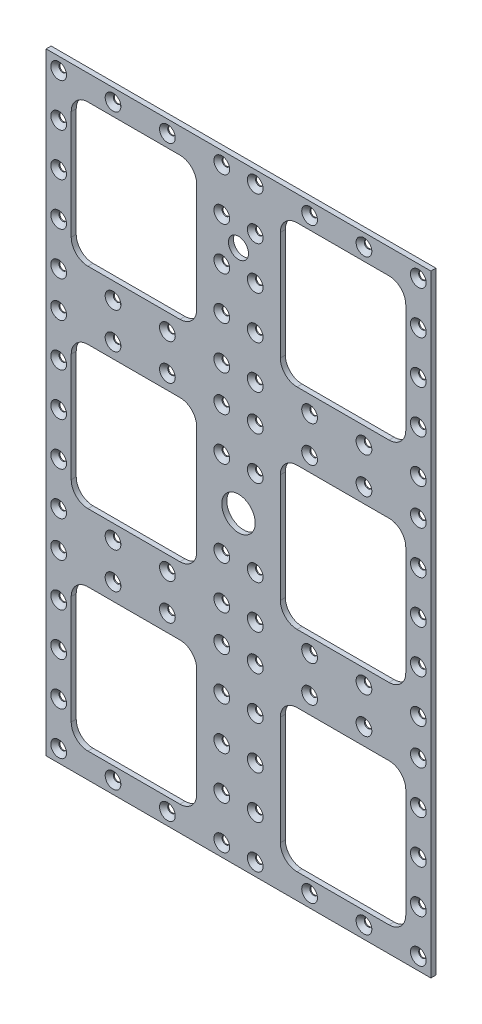
from build123d import *

# Parameters (mm, degrees)
SKETCH1_W                                      = 230
SKETCH1_H                                      = 366
BOSS_EXTRUDE1_DEPTH                            = 3
SKETCH2_W                                      = 75
SKETCH2_H                                      = 85
CUT_EXTRUDE4_DEPTH                             = 4
FILLET1_R                                      = 10
LPATTERN1_COUNT                                = 3
LPATTERN1_PITCH                                = 125.5
LPATTERN1_COUNT_DIR2                           = 2
LPATTERN1_PITCH_DIR2                           = 125
FILLET1_OF_LPATTERN1_R                         = 10
CUT_EXTRUDE7_REACH                             = 5
SKETCH23_R                                     = 10
CSK_FOR_M4_FLAT_HEAD_MACHINE_SCREW5_AT_2_COUNT = 2
CSK_FOR_M4_FLAT_HEAD_MACHINE_SCREW5_AT_2_PITCH = 32.5
CSK_FOR_M4_FLAT_HEAD_MACHINE_SCREW5_AT_3_COUNT = 2
CSK_FOR_M4_FLAT_HEAD_MACHINE_SCREW5_AT_3_PITCH = 65
CSK_FOR_M4_FLAT_HEAD_MACHINE_SCREW5_AT_4_COUNT = 2
CSK_FOR_M4_FLAT_HEAD_MACHINE_SCREW5_AT_4_PITCH = 25.65625
CSK_FOR_M4_FLAT_HEAD_MACHINE_SCREW5_AT_5_COUNT = 2
CSK_FOR_M4_FLAT_HEAD_MACHINE_SCREW5_AT_5_PITCH = 51.3125
CSK_FOR_M4_FLAT_HEAD_MACHINE_SCREW5_AT_6_COUNT = 2
CSK_FOR_M4_FLAT_HEAD_MACHINE_SCREW5_AT_6_PITCH = 76.96875
CSK_FOR_M4_FLAT_HEAD_MACHINE_SCREW5_AT_7_COUNT = 2
CSK_FOR_M4_FLAT_HEAD_MACHINE_SCREW5_AT_7_PITCH = 102.625
CSK_FOR_M4_FLAT_HEAD_MACHINE_SCREW5_AT_8_COUNT = 2
CSK_FOR_M4_FLAT_HEAD_MACHINE_SCREW5_AT_8_PITCH = 107.648226298
CSK_FOR_M4_FLAT_HEAD_MACHINE_SCREW5_AT_9_COUNT = 2
CSK_FOR_M4_FLAT_HEAD_MACHINE_SCREW5_AT_9_PITCH = 121.477942957
CSK_FOR_M4_FLAT_HEAD_MACHINE_SCREW5_AT_1_COUNT = 2
CSK_FOR_M4_FLAT_HEAD_MACHINE_SCREW5_AT_1_PITCH = 124.1875
CSK_FOR_M4_FLAT_HEAD_MACHINE_SCREW5_2_COUNT    = 2
CSK_FOR_M4_FLAT_HEAD_MACHINE_SCREW5_2_PITCH    = 128.369720558
CSK_FOR_M4_FLAT_HEAD_MACHINE_SCREW5_3_COUNT    = 2
CSK_FOR_M4_FLAT_HEAD_MACHINE_SCREW5_3_PITCH    = 140.169665607
CSK_FOR_M4_FLAT_HEAD_MACHINE_SCREW5_4_COUNT    = 2
CSK_FOR_M4_FLAT_HEAD_MACHINE_SCREW5_4_PITCH    = 149.84375
CSK_FOR_M4_FLAT_HEAD_MACHINE_SCREW5_5_COUNT    = 2
CSK_FOR_M4_FLAT_HEAD_MACHINE_SCREW5_5_PITCH    = 175.5
CSK_FOR_M4_FLAT_HEAD_MACHINE_SCREW5_6_COUNT    = 2
CSK_FOR_M4_FLAT_HEAD_MACHINE_SCREW5_6_PITCH    = 201.15625
CSK_FOR_M4_FLAT_HEAD_MACHINE_SCREW5_7_COUNT    = 2
CSK_FOR_M4_FLAT_HEAD_MACHINE_SCREW5_7_PITCH    = 226.8125
CSK_FOR_M4_FLAT_HEAD_MACHINE_SCREW5_8_COUNT    = 2
CSK_FOR_M4_FLAT_HEAD_MACHINE_SCREW5_8_PITCH    = 229.129134237
CSK_FOR_M4_FLAT_HEAD_MACHINE_SCREW5_9_COUNT    = 2
CSK_FOR_M4_FLAT_HEAD_MACHINE_SCREW5_9_PITCH    = 235.942599283
CSK_FOR_M4_FLAT_HEAD_MACHINE_SCREW5_10_COUNT   = 2
CSK_FOR_M4_FLAT_HEAD_MACHINE_SCREW5_10_PITCH   = 256.739441117
CSK_FOR_M4_FLAT_HEAD_MACHINE_SCREW5_11_COUNT   = 2
CSK_FOR_M4_FLAT_HEAD_MACHINE_SCREW5_11_PITCH   = 250.492296538
CSK_FOR_M4_FLAT_HEAD_MACHINE_SCREW5_12_COUNT   = 2
CSK_FOR_M4_FLAT_HEAD_MACHINE_SCREW5_12_PITCH   = 248.375
CSK_FOR_M4_FLAT_HEAD_MACHINE_SCREW5_13_COUNT   = 2
CSK_FOR_M4_FLAT_HEAD_MACHINE_SCREW5_13_PITCH   = 274.03125
CSK_FOR_M4_FLAT_HEAD_MACHINE_SCREW5_14_COUNT   = 2
CSK_FOR_M4_FLAT_HEAD_MACHINE_SCREW5_14_PITCH   = 299.6875
CSK_FOR_M4_FLAT_HEAD_MACHINE_SCREW5_15_COUNT   = 2
CSK_FOR_M4_FLAT_HEAD_MACHINE_SCREW5_15_PITCH   = 325.34375
CSK_FOR_M4_FLAT_HEAD_MACHINE_SCREW5_16_COUNT   = 2
CSK_FOR_M4_FLAT_HEAD_MACHINE_SCREW5_16_PITCH   = 351
CSK_FOR_M4_FLAT_HEAD_MACHINE_SCREW5_17_COUNT   = 2
CSK_FOR_M4_FLAT_HEAD_MACHINE_SCREW5_17_PITCH   = 352.501418437
CSK_FOR_M4_FLAT_HEAD_MACHINE_SCREW5_18_COUNT   = 2
CSK_FOR_M4_FLAT_HEAD_MACHINE_SCREW5_18_PITCH   = 356.967785661
CSK_FOR_M4_FLAT_HEAD_MACHINE_SCREW5_19_COUNT   = 2
CSK_FOR_M4_FLAT_HEAD_MACHINE_SCREW5_19_PITCH   = 182.5
CSK_FOR_M4_FLAT_HEAD_MACHINE_SCREW5_20_COUNT   = 2
CSK_FOR_M4_FLAT_HEAD_MACHINE_SCREW5_20_PITCH   = 215
CSK_FOR_M4_FLAT_HEAD_MACHINE_SCREW5_21_COUNT   = 2
CSK_FOR_M4_FLAT_HEAD_MACHINE_SCREW5_21_PITCH   = 216.525386881
CSK_FOR_M4_FLAT_HEAD_MACHINE_SCREW5_22_COUNT   = 2
CSK_FOR_M4_FLAT_HEAD_MACHINE_SCREW5_22_PITCH   = 221.038396339
CSK_FOR_M4_FLAT_HEAD_MACHINE_SCREW5_23_COUNT   = 2
CSK_FOR_M4_FLAT_HEAD_MACHINE_SCREW5_23_PITCH   = 228.361968105
CSK_FOR_M4_FLAT_HEAD_MACHINE_SCREW5_24_COUNT   = 2
CSK_FOR_M4_FLAT_HEAD_MACHINE_SCREW5_24_PITCH   = 238.23704713
CSK_FOR_M4_FLAT_HEAD_MACHINE_SCREW5_25_COUNT   = 2
CSK_FOR_M4_FLAT_HEAD_MACHINE_SCREW5_25_PITCH   = 97.5
CSK_FOR_M4_FLAT_HEAD_MACHINE_SCREW5_26_COUNT   = 2
CSK_FOR_M4_FLAT_HEAD_MACHINE_SCREW5_26_PITCH   = 209.375597014
CSK_FOR_M4_FLAT_HEAD_MACHINE_SCREW5_27_COUNT   = 2
CSK_FOR_M4_FLAT_HEAD_MACHINE_SCREW5_27_PITCH   = 117.5
CSK_FOR_M4_FLAT_HEAD_MACHINE_SCREW5_28_COUNT   = 2
CSK_FOR_M4_FLAT_HEAD_MACHINE_SCREW5_28_PITCH   = 181.746776106
CSK_FOR_M4_FLAT_HEAD_MACHINE_SCREW5_29_COUNT   = 2
CSK_FOR_M4_FLAT_HEAD_MACHINE_SCREW5_29_PITCH   = 194.7370924
CSK_FOR_M4_FLAT_HEAD_MACHINE_SCREW5_30_COUNT   = 2
CSK_FOR_M4_FLAT_HEAD_MACHINE_SCREW5_30_PITCH   = 220.74597427
CSK_FOR_M4_FLAT_HEAD_MACHINE_SCREW5_31_COUNT   = 2
CSK_FOR_M4_FLAT_HEAD_MACHINE_SCREW5_31_PITCH   = 248.289216754
CSK_FOR_M4_FLAT_HEAD_MACHINE_SCREW5_32_COUNT   = 2
CSK_FOR_M4_FLAT_HEAD_MACHINE_SCREW5_32_PITCH   = 262.065162534
CSK_FOR_M4_FLAT_HEAD_MACHINE_SCREW5_33_COUNT   = 2
CSK_FOR_M4_FLAT_HEAD_MACHINE_SCREW5_33_PITCH   = 277.534232123
CSK_FOR_M4_FLAT_HEAD_MACHINE_SCREW5_34_COUNT   = 2
CSK_FOR_M4_FLAT_HEAD_MACHINE_SCREW5_34_PITCH   = 294.429680763
CSK_FOR_M4_FLAT_HEAD_MACHINE_SCREW5_35_COUNT   = 2
CSK_FOR_M4_FLAT_HEAD_MACHINE_SCREW5_35_PITCH   = 100.819111105
CSK_FOR_M4_FLAT_HEAD_MACHINE_SCREW5_36_COUNT   = 2
CSK_FOR_M4_FLAT_HEAD_MACHINE_SCREW5_36_PITCH   = 312.520255594
CSK_FOR_M4_FLAT_HEAD_MACHINE_SCREW5_37_COUNT   = 2
CSK_FOR_M4_FLAT_HEAD_MACHINE_SCREW5_37_PITCH   = 120.268421309
CSK_FOR_M4_FLAT_HEAD_MACHINE_SCREW5_38_COUNT   = 2
CSK_FOR_M4_FLAT_HEAD_MACHINE_SCREW5_38_PITCH   = 291.118807631
CSK_FOR_M4_FLAT_HEAD_MACHINE_SCREW5_39_COUNT   = 2
CSK_FOR_M4_FLAT_HEAD_MACHINE_SCREW5_39_PITCH   = 110.178140555
CSK_FOR_M4_FLAT_HEAD_MACHINE_SCREW5_40_COUNT   = 2
CSK_FOR_M4_FLAT_HEAD_MACHINE_SCREW5_40_PITCH   = 271.926295448
CSK_FOR_M4_FLAT_HEAD_MACHINE_SCREW5_41_COUNT   = 2
CSK_FOR_M4_FLAT_HEAD_MACHINE_SCREW5_41_PITCH   = 128.21553204
CSK_FOR_M4_FLAT_HEAD_MACHINE_SCREW5_42_COUNT   = 2
CSK_FOR_M4_FLAT_HEAD_MACHINE_SCREW5_42_PITCH   = 290.155373249
CSK_FOR_M4_FLAT_HEAD_MACHINE_SCREW5_43_COUNT   = 2
CSK_FOR_M4_FLAT_HEAD_MACHINE_SCREW5_43_PITCH   = 124.219316036
CSK_FOR_M4_FLAT_HEAD_MACHINE_SCREW5_44_COUNT   = 2
CSK_FOR_M4_FLAT_HEAD_MACHINE_SCREW5_44_PITCH   = 308.214844913
CSK_FOR_M4_FLAT_HEAD_MACHINE_SCREW5_45_COUNT   = 2
CSK_FOR_M4_FLAT_HEAD_MACHINE_SCREW5_45_PITCH   = 140.465079207
CSK_FOR_M4_FLAT_HEAD_MACHINE_SCREW5_46_COUNT   = 2
CSK_FOR_M4_FLAT_HEAD_MACHINE_SCREW5_46_PITCH   = 150
CSK_FOR_M4_FLAT_HEAD_MACHINE_SCREW5_47_COUNT   = 2
CSK_FOR_M4_FLAT_HEAD_MACHINE_SCREW5_47_PITCH   = 328.504399704
CSK_FOR_M4_FLAT_HEAD_MACHINE_SCREW5_48_COUNT   = 2
CSK_FOR_M4_FLAT_HEAD_MACHINE_SCREW5_48_PITCH   = 348.307516394
CSK_FOR_M4_FLAT_HEAD_MACHINE_SCREW5_49_COUNT   = 2
CSK_FOR_M4_FLAT_HEAD_MACHINE_SCREW5_49_PITCH   = 368.832750249
CSK_FOR_M4_FLAT_HEAD_MACHINE_SCREW5_50_COUNT   = 2
CSK_FOR_M4_FLAT_HEAD_MACHINE_SCREW5_50_PITCH   = 389.966095531
CSK_FOR_M4_FLAT_HEAD_MACHINE_SCREW5_51_COUNT   = 2
CSK_FOR_M4_FLAT_HEAD_MACHINE_SCREW5_51_PITCH   = 411.613896753
CSK_FOR_M4_FLAT_HEAD_MACHINE_SCREW5_52_COUNT   = 2
CSK_FOR_M4_FLAT_HEAD_MACHINE_SCREW5_52_PITCH   = 395.609972068
CSK_FOR_M4_FLAT_HEAD_MACHINE_SCREW5_53_COUNT   = 2
CSK_FOR_M4_FLAT_HEAD_MACHINE_SCREW5_53_PITCH   = 381.708003584
CSK_FOR_M4_FLAT_HEAD_MACHINE_SCREW5_54_COUNT   = 2
CSK_FOR_M4_FLAT_HEAD_MACHINE_SCREW5_54_PITCH   = 141.556139482
CSK_FOR_M4_FLAT_HEAD_MACHINE_SCREW5_55_COUNT   = 2
CSK_FOR_M4_FLAT_HEAD_MACHINE_SCREW5_55_PITCH   = 156.006860827
CSK_FOR_M4_FLAT_HEAD_MACHINE_SCREW5_56_COUNT   = 2
CSK_FOR_M4_FLAT_HEAD_MACHINE_SCREW5_56_PITCH   = 170.964280352
CSK_FOR_M4_FLAT_HEAD_MACHINE_SCREW5_57_COUNT   = 2
CSK_FOR_M4_FLAT_HEAD_MACHINE_SCREW5_57_PITCH   = 157.888521294
CSK_FOR_M4_FLAT_HEAD_MACHINE_SCREW5_58_COUNT   = 2
CSK_FOR_M4_FLAT_HEAD_MACHINE_SCREW5_58_PITCH   = 178.771920094
CSK_FOR_M4_FLAT_HEAD_MACHINE_SCREW5_59_COUNT   = 2
CSK_FOR_M4_FLAT_HEAD_MACHINE_SCREW5_59_PITCH   = 190.419010117
CSK_FOR_M4_FLAT_HEAD_MACHINE_SCREW5_60_COUNT   = 2
CSK_FOR_M4_FLAT_HEAD_MACHINE_SCREW5_60_PITCH   = 370.144904058
CSK_FOR_M4_FLAT_HEAD_MACHINE_SCREW5_61_COUNT   = 2
CSK_FOR_M4_FLAT_HEAD_MACHINE_SCREW5_61_PITCH   = 364.290062999
CSK_FOR_M4_FLAT_HEAD_MACHINE_SCREW5_62_COUNT   = 2
CSK_FOR_M4_FLAT_HEAD_MACHINE_SCREW5_62_PITCH   = 339.639228688
CSK_FOR_M4_FLAT_HEAD_MACHINE_SCREW5_63_COUNT   = 2
CSK_FOR_M4_FLAT_HEAD_MACHINE_SCREW5_63_PITCH   = 315.148929327
CSK_FOR_M4_FLAT_HEAD_MACHINE_SCREW5_64_COUNT   = 2
CSK_FOR_M4_FLAT_HEAD_MACHINE_SCREW5_64_PITCH   = 290.859718725
CSK_FOR_M4_FLAT_HEAD_MACHINE_SCREW5_65_COUNT   = 2
CSK_FOR_M4_FLAT_HEAD_MACHINE_SCREW5_65_PITCH   = 266.826517844
CSK_FOR_M4_FLAT_HEAD_MACHINE_SCREW5_66_COUNT   = 2
CSK_FOR_M4_FLAT_HEAD_MACHINE_SCREW5_66_PITCH   = 345.911557575
CSK_FOR_M4_FLAT_HEAD_MACHINE_SCREW5_67_COUNT   = 2
CSK_FOR_M4_FLAT_HEAD_MACHINE_SCREW5_67_PITCH   = 321.898815866
CSK_FOR_M4_FLAT_HEAD_MACHINE_SCREW5_68_COUNT   = 2
CSK_FOR_M4_FLAT_HEAD_MACHINE_SCREW5_68_PITCH   = 298.159983862
CSK_FOR_M4_FLAT_HEAD_MACHINE_SCREW5_69_COUNT   = 2
CSK_FOR_M4_FLAT_HEAD_MACHINE_SCREW5_69_PITCH   = 274.766065272
CSK_FOR_M4_FLAT_HEAD_MACHINE_SCREW5_70_COUNT   = 2
CSK_FOR_M4_FLAT_HEAD_MACHINE_SCREW5_70_PITCH   = 255.441108979
CSK_FOR_M4_FLAT_HEAD_MACHINE_SCREW5_71_COUNT   = 2
CSK_FOR_M4_FLAT_HEAD_MACHINE_SCREW5_71_PITCH   = 246.880862272
CSK_FOR_M4_FLAT_HEAD_MACHINE_SCREW5_72_COUNT   = 2
CSK_FOR_M4_FLAT_HEAD_MACHINE_SCREW5_72_PITCH   = 232.959410443
CSK_FOR_M4_FLAT_HEAD_MACHINE_SCREW5_73_COUNT   = 2
CSK_FOR_M4_FLAT_HEAD_MACHINE_SCREW5_73_PITCH   = 223.539900049
CUT_EXTRUDE8_REACH                             = 5
SKETCH26_R                                     = 6


with BuildPart() as part:
    # Sketch1 → Boss-Extrude1 (new body)
    with BuildSketch(Plane.XY):
        Rectangle(SKETCH1_W, SKETCH1_H)
    extrude(amount=BOSS_EXTRUDE1_DEPTH)

    # Sketch2 → Cut-Extrude4 (cut, through all)
    with BuildSketch(Plane.XY):
        with Locations((-62.5, 125.5)):
            Rectangle(SKETCH2_W, SKETCH2_H)
    cut_extrude4 = extrude(amount=CUT_EXTRUDE4_DEPTH, mode=Mode.SUBTRACT)

    # Fillet1
    fillet1_edges = [part.edges().sort_by_distance(p)[0] for p in [
        (-25, 83, 1.5),
        (-25, 168, 1.5),
        (-100, 168, 1.5),
        (-100, 83, 1.5),
    ]]
    fillet(fillet1_edges, radius=FILLET1_R)

    # LPattern1: Cut-Extrude4 3 × 2
    with Locations(*[(j * LPATTERN1_PITCH_DIR2, -i * LPATTERN1_PITCH, 0) for i in range(LPATTERN1_COUNT) for j in range(LPATTERN1_COUNT_DIR2) if (i, j) != (0, 0)]):
        add(cut_extrude4, mode=Mode.SUBTRACT)

    # Fillet1 of LPattern1
    fillet1_of_lpattern1_edges = [part.edges().sort_by_distance(p)[0] for p in [
        (100, 83, 1.5),
        (100, 168, 1.5),
        (25, 168, 1.5),
        (25, 83, 1.5),
        (-25, -42.5, 1.5),
        (-25, 42.5, 1.5),
        (-100, 42.5, 1.5),
        (-100, -42.5, 1.5),
        (100, -42.5, 1.5),
        (100, 42.5, 1.5),
        (25, 42.5, 1.5),
        (25, -42.5, 1.5),
        (-25, -168, 1.5),
        (-25, -83, 1.5),
        (-100, -83, 1.5),
        (-100, -168, 1.5),
        (100, -168, 1.5),
        (100, -83, 1.5),
        (25, -83, 1.5),
        (25, -168, 1.5),
    ]]
    fillet(fillet1_of_lpattern1_edges, radius=FILLET1_OF_LPATTERN1_R)

    # Sketch23 → Cut-Extrude7 (cut, up to next)
    with BuildSketch(Plane.XY.offset(3), mode=Mode.PRIVATE) as cut_extrude7_sk1:
        Circle(SKETCH23_R)
    cut_extrude7_tool1 = extrude(cut_extrude7_sk1.sketch, amount=-CUT_EXTRUDE7_REACH, mode=Mode.PRIVATE) & part.part
    add(cut_extrude7_tool1.solids().sort_by_distance((0, 0, 3))[0], mode=Mode.SUBTRACT)

    # Sketch25 → CSK for M4 Flat Head Machine Screw5 (revolve, cut)
    with BuildSketch(Plane(origin=(107.5, 175.5, 3), x_dir=(0, -1, 0), z_dir=(1, 0, 0))):
        Polygon((0, 0), (0, 3), (2.25, 3), (2.25, 2.45), (4.7, 0), align=None)
    csk_for_m4_flat_head_machine_screw5 = revolve(axis=Axis((107.5, 175.5, 9.35), (0, 0, -1)), mode=Mode.SUBTRACT)

    # CSK for M4 Flat Head Machine Screw5 at 2: CSK for M4 Flat Head Machine Screw5 ×2
    with Locations(*[(-i * CSK_FOR_M4_FLAT_HEAD_MACHINE_SCREW5_AT_2_PITCH, 0, 0) for i in range(1, CSK_FOR_M4_FLAT_HEAD_MACHINE_SCREW5_AT_2_COUNT)]):
        add(csk_for_m4_flat_head_machine_screw5, mode=Mode.SUBTRACT)

    # CSK for M4 Flat Head Machine Screw5 at 3: CSK for M4 Flat Head Machine Screw5 ×2
    with Locations(*[(-i * CSK_FOR_M4_FLAT_HEAD_MACHINE_SCREW5_AT_3_PITCH, 0, 0) for i in range(1, CSK_FOR_M4_FLAT_HEAD_MACHINE_SCREW5_AT_3_COUNT)]):
        add(csk_for_m4_flat_head_machine_screw5, mode=Mode.SUBTRACT)

    # CSK for M4 Flat Head Machine Screw5 at 4: CSK for M4 Flat Head Machine Screw5 ×2
    with Locations(*[(0, -i * CSK_FOR_M4_FLAT_HEAD_MACHINE_SCREW5_AT_4_PITCH, 0) for i in range(1, CSK_FOR_M4_FLAT_HEAD_MACHINE_SCREW5_AT_4_COUNT)]):
        add(csk_for_m4_flat_head_machine_screw5, mode=Mode.SUBTRACT)

    # CSK for M4 Flat Head Machine Screw5 at 5: CSK for M4 Flat Head Machine Screw5 ×2
    with Locations(*[(0, -i * CSK_FOR_M4_FLAT_HEAD_MACHINE_SCREW5_AT_5_PITCH, 0) for i in range(1, CSK_FOR_M4_FLAT_HEAD_MACHINE_SCREW5_AT_5_COUNT)]):
        add(csk_for_m4_flat_head_machine_screw5, mode=Mode.SUBTRACT)

    # CSK for M4 Flat Head Machine Screw5 at 6: CSK for M4 Flat Head Machine Screw5 ×2
    with Locations(*[(0, -i * CSK_FOR_M4_FLAT_HEAD_MACHINE_SCREW5_AT_6_PITCH, 0) for i in range(1, CSK_FOR_M4_FLAT_HEAD_MACHINE_SCREW5_AT_6_COUNT)]):
        add(csk_for_m4_flat_head_machine_screw5, mode=Mode.SUBTRACT)

    # CSK for M4 Flat Head Machine Screw5 at 7: CSK for M4 Flat Head Machine Screw5 ×2
    with Locations(*[(0, -i * CSK_FOR_M4_FLAT_HEAD_MACHINE_SCREW5_AT_7_PITCH, 0) for i in range(1, CSK_FOR_M4_FLAT_HEAD_MACHINE_SCREW5_AT_7_COUNT)]):
        add(csk_for_m4_flat_head_machine_screw5, mode=Mode.SUBTRACT)

    # CSK for M4 Flat Head Machine Screw5 at 8: CSK for M4 Flat Head Machine Screw5 ×2
    with Locations(*[Vector(-0.301909294, -0.953336655, 0) * (i * CSK_FOR_M4_FLAT_HEAD_MACHINE_SCREW5_AT_8_PITCH) for i in range(1, CSK_FOR_M4_FLAT_HEAD_MACHINE_SCREW5_AT_8_COUNT)]):
        add(csk_for_m4_flat_head_machine_screw5, mode=Mode.SUBTRACT)

    # CSK for M4 Flat Head Machine Screw5 at 9: CSK for M4 Flat Head Machine Screw5 ×2
    with Locations(*[Vector(-0.535076561, -0.844803571, 0) * (i * CSK_FOR_M4_FLAT_HEAD_MACHINE_SCREW5_AT_9_PITCH) for i in range(1, CSK_FOR_M4_FLAT_HEAD_MACHINE_SCREW5_AT_9_COUNT)]):
        add(csk_for_m4_flat_head_machine_screw5, mode=Mode.SUBTRACT)

    # CSK for M4 Flat Head Machine Screw5 at 1: CSK for M4 Flat Head Machine Screw5 ×2
    with Locations(*[(0, -i * CSK_FOR_M4_FLAT_HEAD_MACHINE_SCREW5_AT_1_PITCH, 0) for i in range(1, CSK_FOR_M4_FLAT_HEAD_MACHINE_SCREW5_AT_1_COUNT)]):
        add(csk_for_m4_flat_head_machine_screw5, mode=Mode.SUBTRACT)

    # CSK for M4 Flat Head Machine Screw5  2: CSK for M4 Flat Head Machine Screw5 ×2
    with Locations(*[Vector(-0.253174969, -0.967420506, 0) * (i * CSK_FOR_M4_FLAT_HEAD_MACHINE_SCREW5_2_PITCH) for i in range(1, CSK_FOR_M4_FLAT_HEAD_MACHINE_SCREW5_2_COUNT)]):
        add(csk_for_m4_flat_head_machine_screw5, mode=Mode.SUBTRACT)

    # CSK for M4 Flat Head Machine Screw5  3: CSK for M4 Flat Head Machine Screw5 ×2
    with Locations(*[Vector(-0.463723729, -0.885979855, 0) * (i * CSK_FOR_M4_FLAT_HEAD_MACHINE_SCREW5_3_PITCH) for i in range(1, CSK_FOR_M4_FLAT_HEAD_MACHINE_SCREW5_3_COUNT)]):
        add(csk_for_m4_flat_head_machine_screw5, mode=Mode.SUBTRACT)

    # CSK for M4 Flat Head Machine Screw5  4: CSK for M4 Flat Head Machine Screw5 ×2
    with Locations(*[(0, -i * CSK_FOR_M4_FLAT_HEAD_MACHINE_SCREW5_4_PITCH, 0) for i in range(1, CSK_FOR_M4_FLAT_HEAD_MACHINE_SCREW5_4_COUNT)]):
        add(csk_for_m4_flat_head_machine_screw5, mode=Mode.SUBTRACT)

    # CSK for M4 Flat Head Machine Screw5  5: CSK for M4 Flat Head Machine Screw5 ×2
    with Locations(*[(0, -i * CSK_FOR_M4_FLAT_HEAD_MACHINE_SCREW5_5_PITCH, 0) for i in range(1, CSK_FOR_M4_FLAT_HEAD_MACHINE_SCREW5_5_COUNT)]):
        add(csk_for_m4_flat_head_machine_screw5, mode=Mode.SUBTRACT)

    # CSK for M4 Flat Head Machine Screw5  6: CSK for M4 Flat Head Machine Screw5 ×2
    with Locations(*[(0, -i * CSK_FOR_M4_FLAT_HEAD_MACHINE_SCREW5_6_PITCH, 0) for i in range(1, CSK_FOR_M4_FLAT_HEAD_MACHINE_SCREW5_6_COUNT)]):
        add(csk_for_m4_flat_head_machine_screw5, mode=Mode.SUBTRACT)

    # CSK for M4 Flat Head Machine Screw5  7: CSK for M4 Flat Head Machine Screw5 ×2
    with Locations(*[(0, -i * CSK_FOR_M4_FLAT_HEAD_MACHINE_SCREW5_7_PITCH, 0) for i in range(1, CSK_FOR_M4_FLAT_HEAD_MACHINE_SCREW5_7_COUNT)]):
        add(csk_for_m4_flat_head_machine_screw5, mode=Mode.SUBTRACT)

    # CSK for M4 Flat Head Machine Screw5  8: CSK for M4 Flat Head Machine Screw5 ×2
    with Locations(*[Vector(-0.141841412, -0.989889395, 0) * (i * CSK_FOR_M4_FLAT_HEAD_MACHINE_SCREW5_8_PITCH) for i in range(1, CSK_FOR_M4_FLAT_HEAD_MACHINE_SCREW5_8_COUNT)]):
        add(csk_for_m4_flat_head_machine_screw5, mode=Mode.SUBTRACT)

    # CSK for M4 Flat Head Machine Screw5  9: CSK for M4 Flat Head Machine Screw5 ×2
    with Locations(*[Vector(-0.275490735, -0.961303727, 0) * (i * CSK_FOR_M4_FLAT_HEAD_MACHINE_SCREW5_9_PITCH) for i in range(1, CSK_FOR_M4_FLAT_HEAD_MACHINE_SCREW5_9_COUNT)]):
        add(csk_for_m4_flat_head_machine_screw5, mode=Mode.SUBTRACT)

    # CSK for M4 Flat Head Machine Screw5  10: CSK for M4 Flat Head Machine Screw5 ×2
    with Locations(*[Vector(-0.253174969, -0.967420506, 0) * (i * CSK_FOR_M4_FLAT_HEAD_MACHINE_SCREW5_10_PITCH) for i in range(1, CSK_FOR_M4_FLAT_HEAD_MACHINE_SCREW5_10_COUNT)]):
        add(csk_for_m4_flat_head_machine_screw5, mode=Mode.SUBTRACT)

    # CSK for M4 Flat Head Machine Screw5  11: CSK for M4 Flat Head Machine Screw5 ×2
    with Locations(*[Vector(-0.129744509, -0.991547458, 0) * (i * CSK_FOR_M4_FLAT_HEAD_MACHINE_SCREW5_11_PITCH) for i in range(1, CSK_FOR_M4_FLAT_HEAD_MACHINE_SCREW5_11_COUNT)]):
        add(csk_for_m4_flat_head_machine_screw5, mode=Mode.SUBTRACT)

    # CSK for M4 Flat Head Machine Screw5  12: CSK for M4 Flat Head Machine Screw5 ×2
    with Locations(*[(0, -i * CSK_FOR_M4_FLAT_HEAD_MACHINE_SCREW5_12_PITCH, 0) for i in range(1, CSK_FOR_M4_FLAT_HEAD_MACHINE_SCREW5_12_COUNT)]):
        add(csk_for_m4_flat_head_machine_screw5, mode=Mode.SUBTRACT)

    # CSK for M4 Flat Head Machine Screw5  13: CSK for M4 Flat Head Machine Screw5 ×2
    with Locations(*[(0, -i * CSK_FOR_M4_FLAT_HEAD_MACHINE_SCREW5_13_PITCH, 0) for i in range(1, CSK_FOR_M4_FLAT_HEAD_MACHINE_SCREW5_13_COUNT)]):
        add(csk_for_m4_flat_head_machine_screw5, mode=Mode.SUBTRACT)

    # CSK for M4 Flat Head Machine Screw5  14: CSK for M4 Flat Head Machine Screw5 ×2
    with Locations(*[(0, -i * CSK_FOR_M4_FLAT_HEAD_MACHINE_SCREW5_14_PITCH, 0) for i in range(1, CSK_FOR_M4_FLAT_HEAD_MACHINE_SCREW5_14_COUNT)]):
        add(csk_for_m4_flat_head_machine_screw5, mode=Mode.SUBTRACT)

    # CSK for M4 Flat Head Machine Screw5  15: CSK for M4 Flat Head Machine Screw5 ×2
    with Locations(*[(0, -i * CSK_FOR_M4_FLAT_HEAD_MACHINE_SCREW5_15_PITCH, 0) for i in range(1, CSK_FOR_M4_FLAT_HEAD_MACHINE_SCREW5_15_COUNT)]):
        add(csk_for_m4_flat_head_machine_screw5, mode=Mode.SUBTRACT)

    # CSK for M4 Flat Head Machine Screw5  16: CSK for M4 Flat Head Machine Screw5 ×2
    with Locations(*[(0, -i * CSK_FOR_M4_FLAT_HEAD_MACHINE_SCREW5_16_PITCH, 0) for i in range(1, CSK_FOR_M4_FLAT_HEAD_MACHINE_SCREW5_16_COUNT)]):
        add(csk_for_m4_flat_head_machine_screw5, mode=Mode.SUBTRACT)

    # CSK for M4 Flat Head Machine Screw5  17: CSK for M4 Flat Head Machine Screw5 ×2
    with Locations(*[Vector(-0.092198211, -0.995740674, 0) * (i * CSK_FOR_M4_FLAT_HEAD_MACHINE_SCREW5_17_PITCH) for i in range(1, CSK_FOR_M4_FLAT_HEAD_MACHINE_SCREW5_17_COUNT)]):
        add(csk_for_m4_flat_head_machine_screw5, mode=Mode.SUBTRACT)

    # CSK for M4 Flat Head Machine Screw5  18: CSK for M4 Flat Head Machine Screw5 ×2
    with Locations(*[Vector(-0.18208926, -0.983282005, 0) * (i * CSK_FOR_M4_FLAT_HEAD_MACHINE_SCREW5_18_PITCH) for i in range(1, CSK_FOR_M4_FLAT_HEAD_MACHINE_SCREW5_18_COUNT)]):
        add(csk_for_m4_flat_head_machine_screw5, mode=Mode.SUBTRACT)

    # CSK for M4 Flat Head Machine Screw5  19: CSK for M4 Flat Head Machine Screw5 ×2
    with Locations(*[(-i * CSK_FOR_M4_FLAT_HEAD_MACHINE_SCREW5_19_PITCH, 0, 0) for i in range(1, CSK_FOR_M4_FLAT_HEAD_MACHINE_SCREW5_19_COUNT)]):
        add(csk_for_m4_flat_head_machine_screw5, mode=Mode.SUBTRACT)

    # CSK for M4 Flat Head Machine Screw5  20: CSK for M4 Flat Head Machine Screw5 ×2
    with Locations(*[(-i * CSK_FOR_M4_FLAT_HEAD_MACHINE_SCREW5_20_PITCH, 0, 0) for i in range(1, CSK_FOR_M4_FLAT_HEAD_MACHINE_SCREW5_20_COUNT)]):
        add(csk_for_m4_flat_head_machine_screw5, mode=Mode.SUBTRACT)

    # CSK for M4 Flat Head Machine Screw5  21: CSK for M4 Flat Head Machine Screw5 ×2
    with Locations(*[Vector(-0.992955159, -0.118490725, 0) * (i * CSK_FOR_M4_FLAT_HEAD_MACHINE_SCREW5_21_PITCH) for i in range(1, CSK_FOR_M4_FLAT_HEAD_MACHINE_SCREW5_21_COUNT)]):
        add(csk_for_m4_flat_head_machine_screw5, mode=Mode.SUBTRACT)

    # CSK for M4 Flat Head Machine Screw5  22: CSK for M4 Flat Head Machine Screw5 ×2
    with Locations(*[Vector(-0.972681686, -0.232142926, 0) * (i * CSK_FOR_M4_FLAT_HEAD_MACHINE_SCREW5_22_PITCH) for i in range(1, CSK_FOR_M4_FLAT_HEAD_MACHINE_SCREW5_22_COUNT)]):
        add(csk_for_m4_flat_head_machine_screw5, mode=Mode.SUBTRACT)

    # CSK for M4 Flat Head Machine Screw5  23: CSK for M4 Flat Head Machine Screw5 ×2
    with Locations(*[Vector(-0.94148777, -0.337047148, 0) * (i * CSK_FOR_M4_FLAT_HEAD_MACHINE_SCREW5_23_PITCH) for i in range(1, CSK_FOR_M4_FLAT_HEAD_MACHINE_SCREW5_23_COUNT)]):
        add(csk_for_m4_flat_head_machine_screw5, mode=Mode.SUBTRACT)

    # CSK for M4 Flat Head Machine Screw5  24: CSK for M4 Flat Head Machine Screw5 ×2
    with Locations(*[Vector(-0.902462495, -0.430768435, 0) * (i * CSK_FOR_M4_FLAT_HEAD_MACHINE_SCREW5_24_PITCH) for i in range(1, CSK_FOR_M4_FLAT_HEAD_MACHINE_SCREW5_24_COUNT)]):
        add(csk_for_m4_flat_head_machine_screw5, mode=Mode.SUBTRACT)

    # CSK for M4 Flat Head Machine Screw5  25: CSK for M4 Flat Head Machine Screw5 ×2
    with Locations(*[(-i * CSK_FOR_M4_FLAT_HEAD_MACHINE_SCREW5_25_PITCH, 0, 0) for i in range(1, CSK_FOR_M4_FLAT_HEAD_MACHINE_SCREW5_25_COUNT)]):
        add(csk_for_m4_flat_head_machine_screw5, mode=Mode.SUBTRACT)

    # CSK for M4 Flat Head Machine Screw5  26: CSK for M4 Flat Head Machine Screw5 ×2
    with Locations(*[Vector(-0.871639306, -0.490147856, 0) * (i * CSK_FOR_M4_FLAT_HEAD_MACHINE_SCREW5_26_PITCH) for i in range(1, CSK_FOR_M4_FLAT_HEAD_MACHINE_SCREW5_26_COUNT)]):
        add(csk_for_m4_flat_head_machine_screw5, mode=Mode.SUBTRACT)

    # CSK for M4 Flat Head Machine Screw5  27: CSK for M4 Flat Head Machine Screw5 ×2
    with Locations(*[(-i * CSK_FOR_M4_FLAT_HEAD_MACHINE_SCREW5_27_PITCH, 0, 0) for i in range(1, CSK_FOR_M4_FLAT_HEAD_MACHINE_SCREW5_27_COUNT)]):
        add(csk_for_m4_flat_head_machine_screw5, mode=Mode.SUBTRACT)

    # CSK for M4 Flat Head Machine Screw5  28: CSK for M4 Flat Head Machine Screw5 ×2
    with Locations(*[Vector(-0.825324131, -0.564659259, 0) * (i * CSK_FOR_M4_FLAT_HEAD_MACHINE_SCREW5_28_PITCH) for i in range(1, CSK_FOR_M4_FLAT_HEAD_MACHINE_SCREW5_28_COUNT)]):
        add(csk_for_m4_flat_head_machine_screw5, mode=Mode.SUBTRACT)

    # CSK for M4 Flat Head Machine Screw5  29: CSK for M4 Flat Head Machine Screw5 ×2
    with Locations(*[Vector(-0.77026928, -0.637718775, 0) * (i * CSK_FOR_M4_FLAT_HEAD_MACHINE_SCREW5_29_PITCH) for i in range(1, CSK_FOR_M4_FLAT_HEAD_MACHINE_SCREW5_29_COUNT)]):
        add(csk_for_m4_flat_head_machine_screw5, mode=Mode.SUBTRACT)

    # CSK for M4 Flat Head Machine Screw5  30: CSK for M4 Flat Head Machine Screw5 ×2
    with Locations(*[Vector(-0.826742144, -0.562581041, 0) * (i * CSK_FOR_M4_FLAT_HEAD_MACHINE_SCREW5_30_PITCH) for i in range(1, CSK_FOR_M4_FLAT_HEAD_MACHINE_SCREW5_30_COUNT)]):
        add(csk_for_m4_flat_head_machine_screw5, mode=Mode.SUBTRACT)

    # CSK for M4 Flat Head Machine Screw5  31: CSK for M4 Flat Head Machine Screw5 ×2
    with Locations(*[Vector(-0.865925644, -0.500172749, 0) * (i * CSK_FOR_M4_FLAT_HEAD_MACHINE_SCREW5_31_PITCH) for i in range(1, CSK_FOR_M4_FLAT_HEAD_MACHINE_SCREW5_31_COUNT)]):
        add(csk_for_m4_flat_head_machine_screw5, mode=Mode.SUBTRACT)

    # CSK for M4 Flat Head Machine Screw5  32: CSK for M4 Flat Head Machine Screw5 ×2
    with Locations(*[Vector(-0.820406642, -0.571780501, 0) * (i * CSK_FOR_M4_FLAT_HEAD_MACHINE_SCREW5_32_PITCH) for i in range(1, CSK_FOR_M4_FLAT_HEAD_MACHINE_SCREW5_32_COUNT)]):
        add(csk_for_m4_flat_head_machine_screw5, mode=Mode.SUBTRACT)

    # CSK for M4 Flat Head Machine Screw5  33: CSK for M4 Flat Head Machine Screw5 ×2
    with Locations(*[Vector(-0.774679211, -0.632354426, 0) * (i * CSK_FOR_M4_FLAT_HEAD_MACHINE_SCREW5_33_PITCH) for i in range(1, CSK_FOR_M4_FLAT_HEAD_MACHINE_SCREW5_33_COUNT)]):
        add(csk_for_m4_flat_head_machine_screw5, mode=Mode.SUBTRACT)

    # CSK for M4 Flat Head Machine Screw5  34: CSK for M4 Flat Head Machine Screw5 ×2
    with Locations(*[Vector(-0.730225293, -0.683206426, 0) * (i * CSK_FOR_M4_FLAT_HEAD_MACHINE_SCREW5_34_PITCH) for i in range(1, CSK_FOR_M4_FLAT_HEAD_MACHINE_SCREW5_34_COUNT)]):
        add(csk_for_m4_flat_head_machine_screw5, mode=Mode.SUBTRACT)

    # CSK for M4 Flat Head Machine Screw5  35: CSK for M4 Flat Head Machine Screw5 ×2
    with Locations(*[Vector(-0.967078552, -0.254478042, 0) * (i * CSK_FOR_M4_FLAT_HEAD_MACHINE_SCREW5_35_PITCH) for i in range(1, CSK_FOR_M4_FLAT_HEAD_MACHINE_SCREW5_35_COUNT)]):
        add(csk_for_m4_flat_head_machine_screw5, mode=Mode.SUBTRACT)

    # CSK for M4 Flat Head Machine Screw5  36: CSK for M4 Flat Head Machine Screw5 ×2
    with Locations(*[Vector(-0.687955408, -0.725752958, 0) * (i * CSK_FOR_M4_FLAT_HEAD_MACHINE_SCREW5_36_PITCH) for i in range(1, CSK_FOR_M4_FLAT_HEAD_MACHINE_SCREW5_36_COUNT)]):
        add(csk_for_m4_flat_head_machine_screw5, mode=Mode.SUBTRACT)

    # CSK for M4 Flat Head Machine Screw5  37: CSK for M4 Flat Head Machine Screw5 ×2
    with Locations(*[Vector(-0.976981312, -0.213324909, 0) * (i * CSK_FOR_M4_FLAT_HEAD_MACHINE_SCREW5_37_PITCH) for i in range(1, CSK_FOR_M4_FLAT_HEAD_MACHINE_SCREW5_37_COUNT)]):
        add(csk_for_m4_flat_head_machine_screw5, mode=Mode.SUBTRACT)

    # CSK for M4 Flat Head Machine Screw5  38: CSK for M4 Flat Head Machine Screw5 ×2
    with Locations(*[Vector(-0.626891823, -0.77910631, 0) * (i * CSK_FOR_M4_FLAT_HEAD_MACHINE_SCREW5_38_PITCH) for i in range(1, CSK_FOR_M4_FLAT_HEAD_MACHINE_SCREW5_38_COUNT)]):
        add(csk_for_m4_flat_head_machine_screw5, mode=Mode.SUBTRACT)

    # CSK for M4 Flat Head Machine Screw5  39: CSK for M4 Flat Head Machine Screw5 ×2
    with Locations(*[Vector(-0.884930527, -0.465723053, 0) * (i * CSK_FOR_M4_FLAT_HEAD_MACHINE_SCREW5_39_PITCH) for i in range(1, CSK_FOR_M4_FLAT_HEAD_MACHINE_SCREW5_39_COUNT)]):
        add(csk_for_m4_flat_head_machine_screw5, mode=Mode.SUBTRACT)

    # CSK for M4 Flat Head Machine Screw5  40: CSK for M4 Flat Head Machine Screw5 ×2
    with Locations(*[Vector(-0.551620062, -0.834095502, 0) * (i * CSK_FOR_M4_FLAT_HEAD_MACHINE_SCREW5_40_PITCH) for i in range(1, CSK_FOR_M4_FLAT_HEAD_MACHINE_SCREW5_40_COUNT)]):
        add(csk_for_m4_flat_head_machine_screw5, mode=Mode.SUBTRACT)

    # CSK for M4 Flat Head Machine Screw5  41: CSK for M4 Flat Head Machine Screw5 ×2
    with Locations(*[Vector(-0.916425632, -0.400205023, 0) * (i * CSK_FOR_M4_FLAT_HEAD_MACHINE_SCREW5_41_PITCH) for i in range(1, CSK_FOR_M4_FLAT_HEAD_MACHINE_SCREW5_41_COUNT)]):
        add(csk_for_m4_flat_head_machine_screw5, mode=Mode.SUBTRACT)

    # CSK for M4 Flat Head Machine Screw5  42: CSK for M4 Flat Head Machine Screw5 ×2
    with Locations(*[Vector(-0.516964405, -0.856006895, 0) * (i * CSK_FOR_M4_FLAT_HEAD_MACHINE_SCREW5_42_PITCH) for i in range(1, CSK_FOR_M4_FLAT_HEAD_MACHINE_SCREW5_42_COUNT)]):
        add(csk_for_m4_flat_head_machine_screw5, mode=Mode.SUBTRACT)

    # CSK for M4 Flat Head Machine Screw5  43: CSK for M4 Flat Head Machine Screw5 ×2
    with Locations(*[Vector(-0.784902084, -0.619619818, 0) * (i * CSK_FOR_M4_FLAT_HEAD_MACHINE_SCREW5_43_PITCH) for i in range(1, CSK_FOR_M4_FLAT_HEAD_MACHINE_SCREW5_43_COUNT)]):
        add(csk_for_m4_flat_head_machine_screw5, mode=Mode.SUBTRACT)

    # CSK for M4 Flat Head Machine Screw5  44: CSK for M4 Flat Head Machine Screw5 ×2
    with Locations(*[Vector(-0.592119436, -0.805850218, 0) * (i * CSK_FOR_M4_FLAT_HEAD_MACHINE_SCREW5_44_PITCH) for i in range(1, CSK_FOR_M4_FLAT_HEAD_MACHINE_SCREW5_44_COUNT)]):
        add(csk_for_m4_flat_head_machine_screw5, mode=Mode.SUBTRACT)

    # CSK for M4 Flat Head Machine Screw5  45: CSK for M4 Flat Head Machine Screw5 ×2
    with Locations(*[Vector(-0.836506843, -0.547956477, 0) * (i * CSK_FOR_M4_FLAT_HEAD_MACHINE_SCREW5_45_PITCH) for i in range(1, CSK_FOR_M4_FLAT_HEAD_MACHINE_SCREW5_45_COUNT)]):
        add(csk_for_m4_flat_head_machine_screw5, mode=Mode.SUBTRACT)

    # CSK for M4 Flat Head Machine Screw5  46: CSK for M4 Flat Head Machine Screw5 ×2
    with Locations(*[(-i * CSK_FOR_M4_FLAT_HEAD_MACHINE_SCREW5_46_PITCH, 0, 0) for i in range(1, CSK_FOR_M4_FLAT_HEAD_MACHINE_SCREW5_46_COUNT)]):
        add(csk_for_m4_flat_head_machine_screw5, mode=Mode.SUBTRACT)

    # CSK for M4 Flat Head Machine Screw5  47: CSK for M4 Flat Head Machine Screw5 ×2
    with Locations(*[Vector(-0.654481341, -0.756078154, 0) * (i * CSK_FOR_M4_FLAT_HEAD_MACHINE_SCREW5_47_PITCH) for i in range(1, CSK_FOR_M4_FLAT_HEAD_MACHINE_SCREW5_47_COUNT)]):
        add(csk_for_m4_flat_head_machine_screw5, mode=Mode.SUBTRACT)

    # CSK for M4 Flat Head Machine Screw5  48: CSK for M4 Flat Head Machine Screw5 ×2
    with Locations(*[Vector(-0.61727063, -0.786750894, 0) * (i * CSK_FOR_M4_FLAT_HEAD_MACHINE_SCREW5_48_PITCH) for i in range(1, CSK_FOR_M4_FLAT_HEAD_MACHINE_SCREW5_48_COUNT)]):
        add(csk_for_m4_flat_head_machine_screw5, mode=Mode.SUBTRACT)

    # CSK for M4 Flat Head Machine Screw5  49: CSK for M4 Flat Head Machine Screw5 ×2
    with Locations(*[Vector(-0.582920036, -0.812529527, 0) * (i * CSK_FOR_M4_FLAT_HEAD_MACHINE_SCREW5_49_PITCH) for i in range(1, CSK_FOR_M4_FLAT_HEAD_MACHINE_SCREW5_49_COUNT)]):
        add(csk_for_m4_flat_head_machine_screw5, mode=Mode.SUBTRACT)

    # CSK for M4 Flat Head Machine Screw5  50: CSK for M4 Flat Head Machine Screw5 ×2
    with Locations(*[Vector(-0.551329981, -0.834287272, 0) * (i * CSK_FOR_M4_FLAT_HEAD_MACHINE_SCREW5_50_PITCH) for i in range(1, CSK_FOR_M4_FLAT_HEAD_MACHINE_SCREW5_50_COUNT)]):
        add(csk_for_m4_flat_head_machine_screw5, mode=Mode.SUBTRACT)

    # CSK for M4 Flat Head Machine Screw5  51: CSK for M4 Flat Head Machine Screw5 ×2
    with Locations(*[Vector(-0.522334162, -0.852740888, 0) * (i * CSK_FOR_M4_FLAT_HEAD_MACHINE_SCREW5_51_PITCH) for i in range(1, CSK_FOR_M4_FLAT_HEAD_MACHINE_SCREW5_51_COUNT)]):
        add(csk_for_m4_flat_head_machine_screw5, mode=Mode.SUBTRACT)

    # CSK for M4 Flat Head Machine Screw5  52: CSK for M4 Flat Head Machine Screw5 ×2
    with Locations(*[Vector(-0.461312942, -0.887237493, 0) * (i * CSK_FOR_M4_FLAT_HEAD_MACHINE_SCREW5_52_PITCH) for i in range(1, CSK_FOR_M4_FLAT_HEAD_MACHINE_SCREW5_52_COUNT)]):
        add(csk_for_m4_flat_head_machine_screw5, mode=Mode.SUBTRACT)

    # CSK for M4 Flat Head Machine Screw5  53: CSK for M4 Flat Head Machine Screw5 ×2
    with Locations(*[Vector(-0.392970539, -0.919551062, 0) * (i * CSK_FOR_M4_FLAT_HEAD_MACHINE_SCREW5_53_PITCH) for i in range(1, CSK_FOR_M4_FLAT_HEAD_MACHINE_SCREW5_53_COUNT)]):
        add(csk_for_m4_flat_head_machine_screw5, mode=Mode.SUBTRACT)

    # CSK for M4 Flat Head Machine Screw5  54: CSK for M4 Flat Head Machine Screw5 ×2
    with Locations(*[Vector(-0.688772669, -0.724977386, 0) * (i * CSK_FOR_M4_FLAT_HEAD_MACHINE_SCREW5_54_PITCH) for i in range(1, CSK_FOR_M4_FLAT_HEAD_MACHINE_SCREW5_54_COUNT)]):
        add(csk_for_m4_flat_head_machine_screw5, mode=Mode.SUBTRACT)

    # CSK for M4 Flat Head Machine Screw5  55: CSK for M4 Flat Head Machine Screw5 ×2
    with Locations(*[Vector(-0.753172004, -0.657823633, 0) * (i * CSK_FOR_M4_FLAT_HEAD_MACHINE_SCREW5_55_PITCH) for i in range(1, CSK_FOR_M4_FLAT_HEAD_MACHINE_SCREW5_55_COUNT)]):
        add(csk_for_m4_flat_head_machine_screw5, mode=Mode.SUBTRACT)

    # CSK for M4 Flat Head Machine Screw5  56: CSK for M4 Flat Head Machine Screw5 ×2
    with Locations(*[Vector(-0.687278066, -0.726394424, 0) * (i * CSK_FOR_M4_FLAT_HEAD_MACHINE_SCREW5_56_PITCH) for i in range(1, CSK_FOR_M4_FLAT_HEAD_MACHINE_SCREW5_56_COUNT)]):
        add(csk_for_m4_flat_head_machine_screw5, mode=Mode.SUBTRACT)

    # CSK for M4 Flat Head Machine Screw5  57: CSK for M4 Flat Head Machine Screw5 ×2
    with Locations(*[Vector(-0.617524309, -0.786551796, 0) * (i * CSK_FOR_M4_FLAT_HEAD_MACHINE_SCREW5_57_PITCH) for i in range(1, CSK_FOR_M4_FLAT_HEAD_MACHINE_SCREW5_57_COUNT)]):
        add(csk_for_m4_flat_head_machine_screw5, mode=Mode.SUBTRACT)

    # CSK for M4 Flat Head Machine Screw5  58: CSK for M4 Flat Head Machine Screw5 ×2
    with Locations(*[Vector(-0.545387665, -0.838183927, 0) * (i * CSK_FOR_M4_FLAT_HEAD_MACHINE_SCREW5_58_PITCH) for i in range(1, CSK_FOR_M4_FLAT_HEAD_MACHINE_SCREW5_58_COUNT)]):
        add(csk_for_m4_flat_head_machine_screw5, mode=Mode.SUBTRACT)

    # CSK for M4 Flat Head Machine Screw5  59: CSK for M4 Flat Head Machine Screw5 ×2
    with Locations(*[Vector(-0.61706024, -0.786915917, 0) * (i * CSK_FOR_M4_FLAT_HEAD_MACHINE_SCREW5_59_PITCH) for i in range(1, CSK_FOR_M4_FLAT_HEAD_MACHINE_SCREW5_59_COUNT)]):
        add(csk_for_m4_flat_head_machine_screw5, mode=Mode.SUBTRACT)

    # CSK for M4 Flat Head Machine Screw5  60: CSK for M4 Flat Head Machine Screw5 ×2
    with Locations(*[Vector(-0.317443246, -0.948277272, 0) * (i * CSK_FOR_M4_FLAT_HEAD_MACHINE_SCREW5_60_PITCH) for i in range(1, CSK_FOR_M4_FLAT_HEAD_MACHINE_SCREW5_60_COUNT)]):
        add(csk_for_m4_flat_head_machine_screw5, mode=Mode.SUBTRACT)

    # CSK for M4 Flat Head Machine Screw5  61: CSK for M4 Flat Head Machine Screw5 ×2
    with Locations(*[Vector(-0.267643864, -0.96351791, 0) * (i * CSK_FOR_M4_FLAT_HEAD_MACHINE_SCREW5_61_PITCH) for i in range(1, CSK_FOR_M4_FLAT_HEAD_MACHINE_SCREW5_61_COUNT)]):
        add(csk_for_m4_flat_head_machine_screw5, mode=Mode.SUBTRACT)

    # CSK for M4 Flat Head Machine Screw5  62: CSK for M4 Flat Head Machine Screw5 ×2
    with Locations(*[Vector(-0.287069313, -0.957909813, 0) * (i * CSK_FOR_M4_FLAT_HEAD_MACHINE_SCREW5_62_PITCH) for i in range(1, CSK_FOR_M4_FLAT_HEAD_MACHINE_SCREW5_62_COUNT)]):
        add(csk_for_m4_flat_head_machine_screw5, mode=Mode.SUBTRACT)

    # CSK for M4 Flat Head Machine Screw5  63: CSK for M4 Flat Head Machine Screw5 ×2
    with Locations(*[Vector(-0.309377538, -0.950939293, 0) * (i * CSK_FOR_M4_FLAT_HEAD_MACHINE_SCREW5_63_PITCH) for i in range(1, CSK_FOR_M4_FLAT_HEAD_MACHINE_SCREW5_63_COUNT)]):
        add(csk_for_m4_flat_head_machine_screw5, mode=Mode.SUBTRACT)

    # CSK for M4 Flat Head Machine Screw5  64: CSK for M4 Flat Head Machine Screw5 ×2
    with Locations(*[Vector(-0.335213141, -0.942142319, 0) * (i * CSK_FOR_M4_FLAT_HEAD_MACHINE_SCREW5_64_PITCH) for i in range(1, CSK_FOR_M4_FLAT_HEAD_MACHINE_SCREW5_64_COUNT)]):
        add(csk_for_m4_flat_head_machine_screw5, mode=Mode.SUBTRACT)

    # CSK for M4 Flat Head Machine Screw5  65: CSK for M4 Flat Head Machine Screw5 ×2
    with Locations(*[Vector(-0.36540596, -0.930848261, 0) * (i * CSK_FOR_M4_FLAT_HEAD_MACHINE_SCREW5_65_PITCH) for i in range(1, CSK_FOR_M4_FLAT_HEAD_MACHINE_SCREW5_65_COUNT)]):
        add(csk_for_m4_flat_head_machine_screw5, mode=Mode.SUBTRACT)

    # CSK for M4 Flat Head Machine Screw5  66: CSK for M4 Flat Head Machine Screw5 ×2
    with Locations(*[Vector(-0.339682203, -0.940540271, 0) * (i * CSK_FOR_M4_FLAT_HEAD_MACHINE_SCREW5_66_PITCH) for i in range(1, CSK_FOR_M4_FLAT_HEAD_MACHINE_SCREW5_66_COUNT)]):
        add(csk_for_m4_flat_head_machine_screw5, mode=Mode.SUBTRACT)

    # CSK for M4 Flat Head Machine Screw5  67: CSK for M4 Flat Head Machine Screw5 ×2
    with Locations(*[Vector(-0.365021535, -0.930999076, 0) * (i * CSK_FOR_M4_FLAT_HEAD_MACHINE_SCREW5_67_PITCH) for i in range(1, CSK_FOR_M4_FLAT_HEAD_MACHINE_SCREW5_67_COUNT)]):
        add(csk_for_m4_flat_head_machine_screw5, mode=Mode.SUBTRACT)

    # CSK for M4 Flat Head Machine Screw5  68: CSK for M4 Flat Head Machine Screw5 ×2
    with Locations(*[Vector(-0.394083735, -0.91907454, 0) * (i * CSK_FOR_M4_FLAT_HEAD_MACHINE_SCREW5_68_PITCH) for i in range(1, CSK_FOR_M4_FLAT_HEAD_MACHINE_SCREW5_68_COUNT)]):
        add(csk_for_m4_flat_head_machine_screw5, mode=Mode.SUBTRACT)

    # CSK for M4 Flat Head Machine Screw5  69: CSK for M4 Flat Head Machine Screw5 ×2
    with Locations(*[Vector(-0.427636506, -0.903950784, 0) * (i * CSK_FOR_M4_FLAT_HEAD_MACHINE_SCREW5_69_PITCH) for i in range(1, CSK_FOR_M4_FLAT_HEAD_MACHINE_SCREW5_69_COUNT)]):
        add(csk_for_m4_flat_head_machine_screw5, mode=Mode.SUBTRACT)

    # CSK for M4 Flat Head Machine Screw5  70: CSK for M4 Flat Head Machine Screw5 ×2
    with Locations(*[Vector(-0.459988607, -0.887924817, 0) * (i * CSK_FOR_M4_FLAT_HEAD_MACHINE_SCREW5_70_PITCH) for i in range(1, CSK_FOR_M4_FLAT_HEAD_MACHINE_SCREW5_70_COUNT)]):
        add(csk_for_m4_flat_head_machine_screw5, mode=Mode.SUBTRACT)

    # CSK for M4 Flat Head Machine Screw5  71: CSK for M4 Flat Head Machine Screw5 ×2
    with Locations(*[Vector(-0.394927331, -0.918712362, 0) * (i * CSK_FOR_M4_FLAT_HEAD_MACHINE_SCREW5_71_PITCH) for i in range(1, CSK_FOR_M4_FLAT_HEAD_MACHINE_SCREW5_71_COUNT)]):
        add(csk_for_m4_flat_head_machine_screw5, mode=Mode.SUBTRACT)

    # CSK for M4 Flat Head Machine Screw5  72: CSK for M4 Flat Head Machine Screw5 ×2
    with Locations(*[Vector(-0.504379711, -0.863481967, 0) * (i * CSK_FOR_M4_FLAT_HEAD_MACHINE_SCREW5_72_PITCH) for i in range(1, CSK_FOR_M4_FLAT_HEAD_MACHINE_SCREW5_72_COUNT)]):
        add(csk_for_m4_flat_head_machine_screw5, mode=Mode.SUBTRACT)

    # CSK for M4 Flat Head Machine Screw5  73: CSK for M4 Flat Head Machine Screw5 ×2
    with Locations(*[Vector(-0.436163745, -0.899867317, 0) * (i * CSK_FOR_M4_FLAT_HEAD_MACHINE_SCREW5_73_PITCH) for i in range(1, CSK_FOR_M4_FLAT_HEAD_MACHINE_SCREW5_73_COUNT)]):
        add(csk_for_m4_flat_head_machine_screw5, mode=Mode.SUBTRACT)

    # Sketch26 → Cut-Extrude8 (cut, up to next)
    with BuildSketch(Plane.XY.offset(3), mode=Mode.PRIVATE) as cut_extrude8_sk1:
        with Locations((0, 137.5)):
            Circle(SKETCH26_R)
    cut_extrude8_tool1 = extrude(cut_extrude8_sk1.sketch, amount=-CUT_EXTRUDE8_REACH, mode=Mode.PRIVATE) & part.part
    add(cut_extrude8_tool1.solids().sort_by_distance((0, 137.5, 3))[0], mode=Mode.SUBTRACT)


solid = part.part
